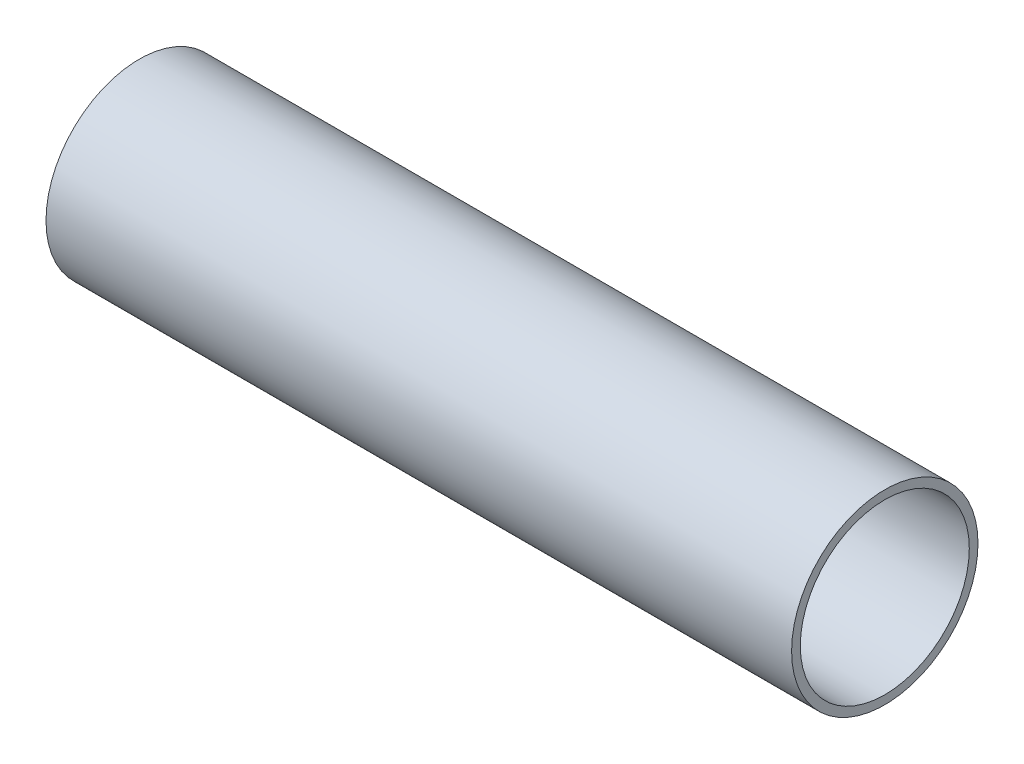
from build123d import *

# Parameters (mm, degrees)
SKETCH1_W = 76.2
SKETCH1_H = 0.889


with BuildPart() as part:
    # Sketch1 → Revolve1 (revolve)
    with BuildSketch(Plane(origin=(0, 0, 0), x_dir=(1, 0, 0), z_dir=(0, 1, 0))):
        with Locations((38.1, 9.0805)):
            Rectangle(SKETCH1_W, SKETCH1_H)
    revolve(axis=Axis((0, 0, 0), (1, 0, 0)))


solid = part.part
